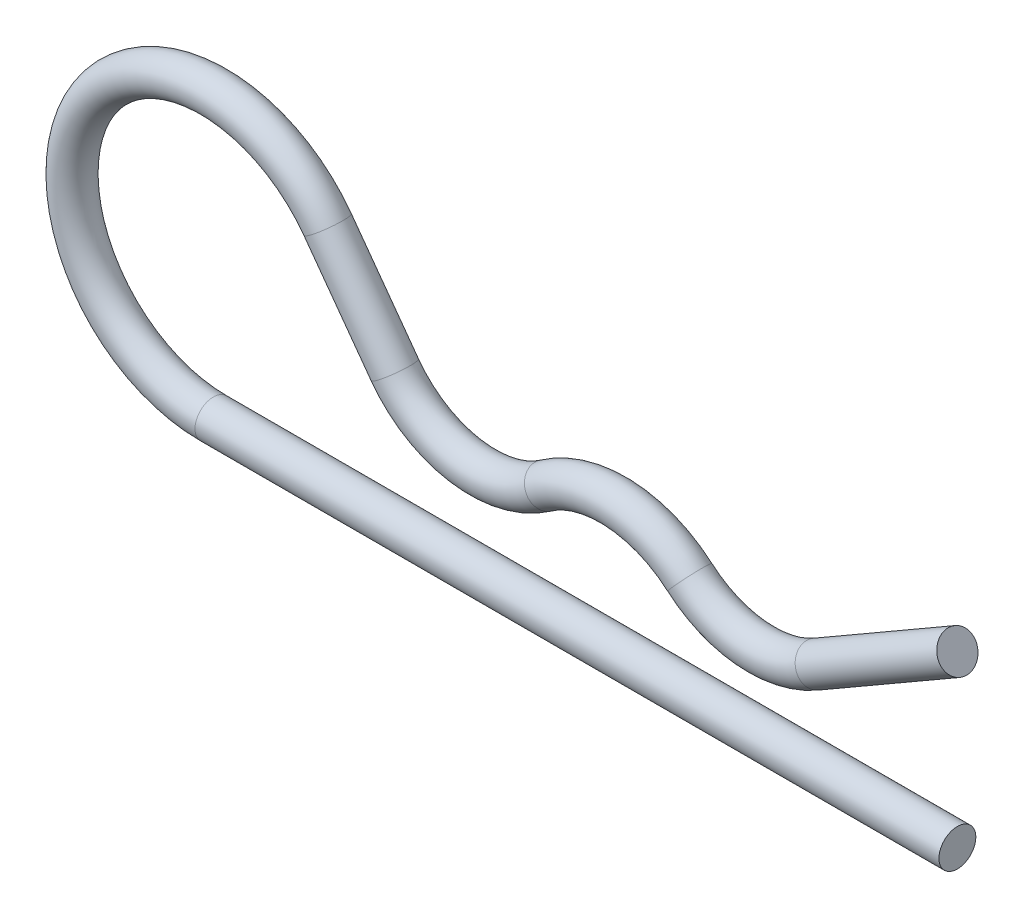
from build123d import *

# Parameters (mm, degrees)
SZKIC2_R = 1.5


with BuildPart() as part:
    # Wyciągnięcie po ścieżce1: sweep along a path in Szkic1
    with BuildLine(Plane.XY) as wyci_gni_cie_po_cie_ce1_path:
        Line((60.5, -11.5), (0, -11.5))
        ThreePointArc((0, -11.5), (-10.250305385, 5.213563034), (9.294019694, 6.772827912))
        Line((9.294019694, 6.772827912), (14.754234774, -0.719957545))
        ThreePointArc((14.754234774, -0.719957545), (20.473785722, -4.243192601), (27.020890568, -2.739242316))
        ThreePointArc((27.020890568, -2.739242316), (32.983788023, -1.012326463), (38.740099231, -3.336819032))
        ThreePointArc((38.740099231, -3.336819032), (43.704455056, -5.474315656), (48.98666307, -4.328890373))
        Line((48.98666307, -4.328890373), (60.5, 2.318337803))
    # Szkic2 → Wyciągnięcie po ścieżce1 (sweep)
    with BuildSketch(Plane(origin=(60.5, -11.5, 0), x_dir=(0, 0, -1), z_dir=(1, 0, 0))):
        Circle(SZKIC2_R)
    sweep(path=wyci_gni_cie_po_cie_ce1_path.line)


solid = part.part
